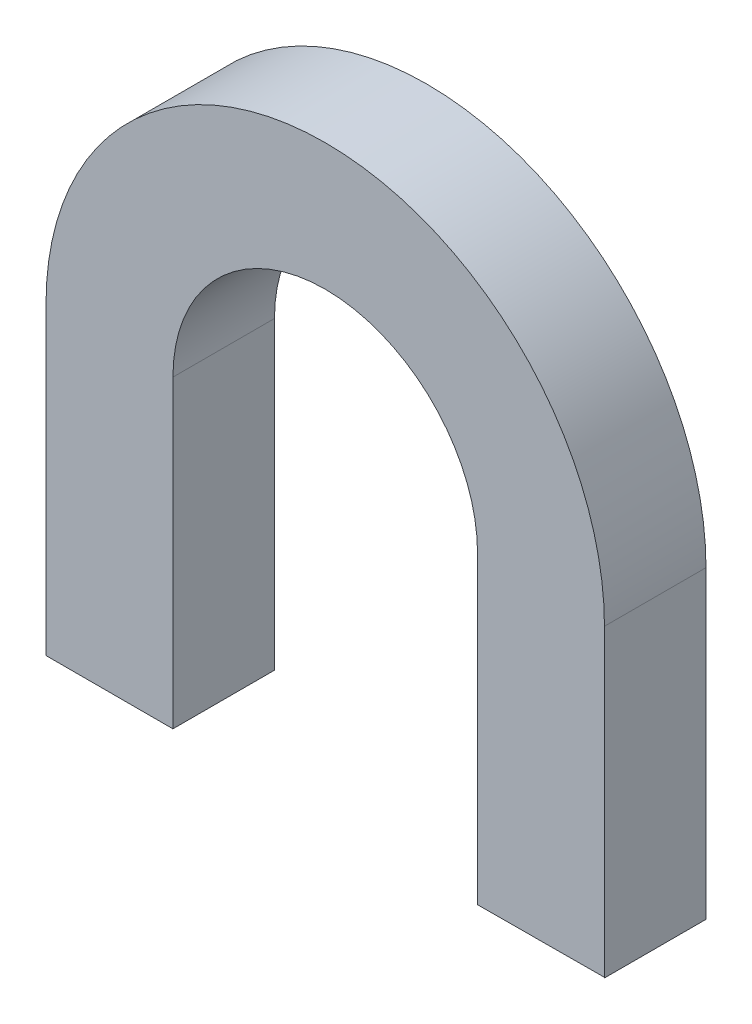
from build123d import *

# Parameters (mm, degrees)
BOSS_EXTRUDE1_DEPTH = 4


with BuildPart() as part:
    # Sketch2 → Boss-Extrude1 (new body)
    with BuildSketch(Plane.XY):
        with BuildLine():
            Line((-37.411863854, 35.187534323), (-37.411863854, 23.187534323))
            Line((-37.411863854, 23.187534323), (-37.440640728, 23.209290717))
            Line((-37.440640728, 23.209290717), (-42.411863854, 23.187534323))
            Line((-42.411863854, 23.187534323), (-42.411863854, 35.187534323))
            ThreePointArc((-42.411863854, 35.187534323), (-48.411863854, 41.187534323), (-54.411863854, 35.187534323))
            Line((-54.411863854, 35.187534323), (-54.411863854, 23.187534323))
            Line((-54.411863854, 23.187534323), (-59.411863854, 23.187534323))
            Line((-59.411863854, 23.187534323), (-59.411863854, 35.187534323))
            ThreePointArc((-59.411863854, 35.187534323), (-48.411863854, 46.187534323), (-37.411863854, 35.187534323))
        make_face()
    extrude(amount=BOSS_EXTRUDE1_DEPTH)


solid = part.part
